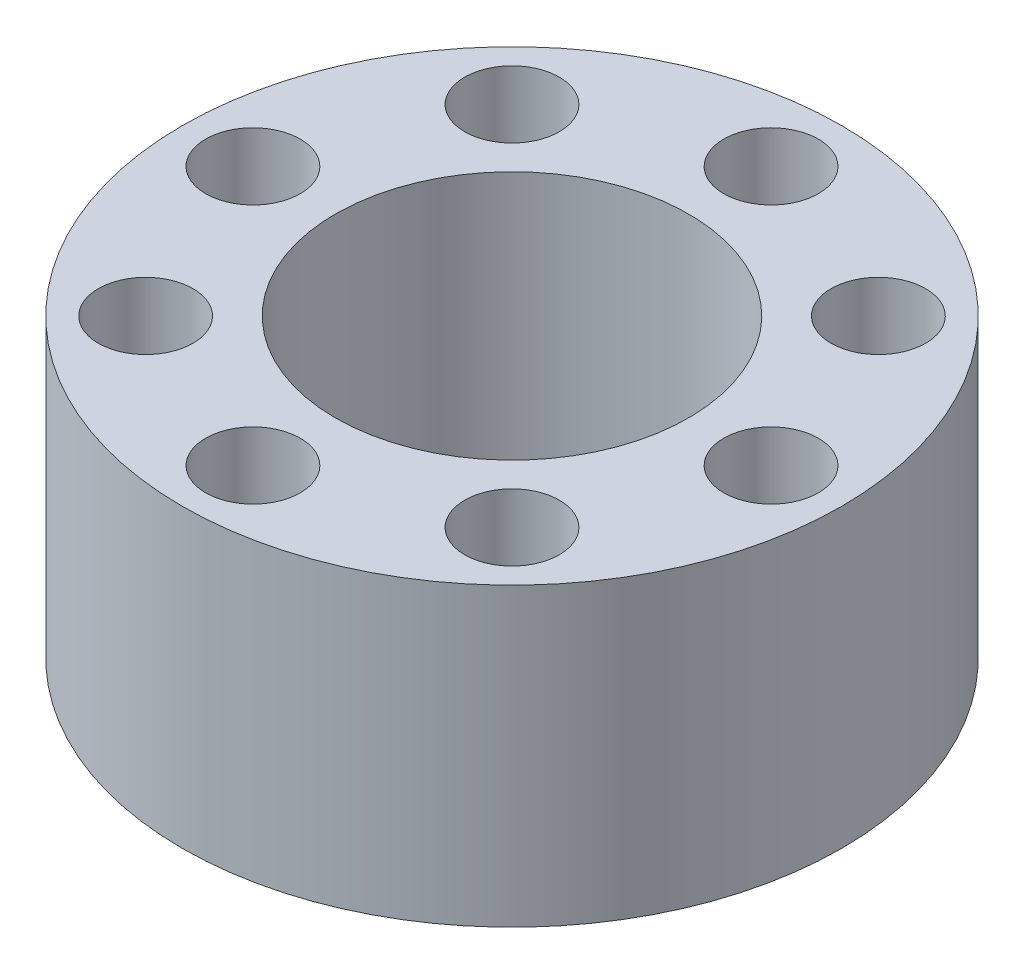
from build123d import *

# Parameters (mm, degrees)
SKETCH1_R           = 17.78
SKETCH1_R_2         = 2.5527
SKETCH1_R_3         = 9.525
BOSS_EXTRUDE1_DEPTH = 15.9766


with BuildPart() as part:
    # Sketch1 → Boss-Extrude1 (new body)
    with BuildSketch(Plane(origin=(0, 0, 0), x_dir=(1, 0, 0), z_dir=(0, 1, 0))):
        Circle(SKETCH1_R)
        with Locations((0, 13.97)):
            Circle(SKETCH1_R_2, mode=Mode.SUBTRACT)
        with Locations((9.878281733, 9.878281733)):
            Circle(SKETCH1_R_2, mode=Mode.SUBTRACT)
        with Locations((13.97, 0)):
            Circle(SKETCH1_R_2, mode=Mode.SUBTRACT)
        with Locations((9.878281733, -9.878281733)):
            Circle(SKETCH1_R_2, mode=Mode.SUBTRACT)
        with Locations((0, -13.97)):
            Circle(SKETCH1_R_2, mode=Mode.SUBTRACT)
        with Locations((-9.878281733, -9.878281733)):
            Circle(SKETCH1_R_2, mode=Mode.SUBTRACT)
        with Locations((-13.97, 0)):
            Circle(SKETCH1_R_2, mode=Mode.SUBTRACT)
        with Locations((-9.878281733, 9.878281733)):
            Circle(SKETCH1_R_2, mode=Mode.SUBTRACT)
        Circle(SKETCH1_R_3, mode=Mode.SUBTRACT)
    extrude(amount=BOSS_EXTRUDE1_DEPTH)


solid = part.part
